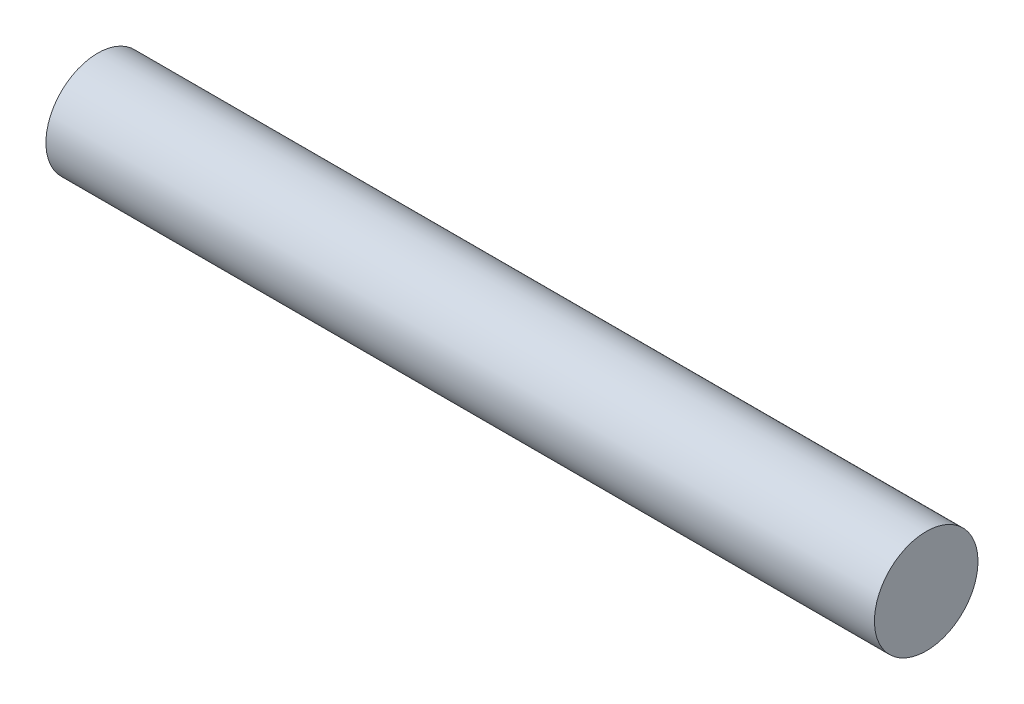
from build123d import *

# Parameters (mm, degrees)
SKETCH1_R           = 25
BOSS_EXTRUDE1_DEPTH = 200


with BuildPart() as part:
    # Sketch1 → Boss-Extrude1 (new body, symmetric)
    with BuildSketch(Plane(origin=(0, 0, 0), x_dir=(0, -1, 0), z_dir=(1, 0, 0))):
        Circle(SKETCH1_R)
    extrude(amount=BOSS_EXTRUDE1_DEPTH, both=True)


solid = part.part
